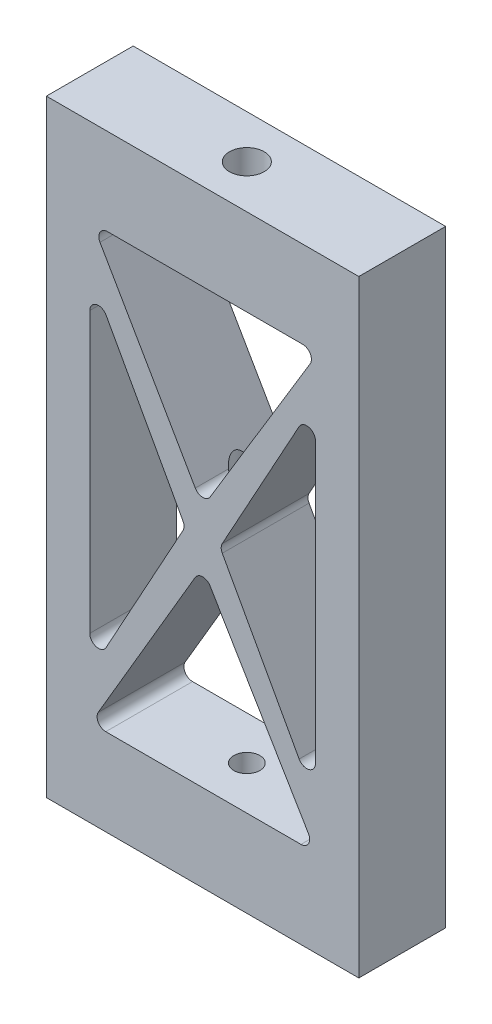
from build123d import *

# Parameters (mm, degrees)
SKIZZE1_W                       = 36
SKIZZE1_H                       = 70
AUFSATZ_LINEAR_AUSTRAGEN1_DEPTH = 10
SKIZZE2_R                       = 1.5
SCHNITT_LINEAR_AUSTRAGEN1_DEPTH = 71
SKIZZE3_R                       = 2
SCHNITT_LINEAR_AUSTRAGEN2_DEPTH = 6
SKIZZE4_R                       = 2
SCHNITT_LINEAR_AUSTRAGEN3_DEPTH = 6


with BuildPart() as part:
    # Skizze1 → Aufsatz-Linear austragen1 (new body)
    with BuildSketch(Plane.XY):
        with Locations((4.904225341, 35)):
            Rectangle(SKIZZE1_W, SKIZZE1_H)
        with BuildLine():
            Line((17.904225341, 51.106779598), (17.904225341, 18.893220402))
            ThreePointArc((17.904225341, 18.893220402), (17.153006461, 17.92466067), (16.028009433, 18.411301652))
            Line((16.028009433, 18.411301652), (7.169280654, 34.51808125))
            ThreePointArc((7.169280654, 34.51808125), (7.045496562, 35), (7.169280654, 35.48191875))
            Line((7.169280654, 35.48191875), (16.028009433, 51.588698348))
            ThreePointArc((16.028009433, 51.588698348), (17.153006461, 52.07533933), (17.904225341, 51.106779598))
        make_face(mode=Mode.SUBTRACT)
        with BuildLine():
            Line((-8.095774659, 51.106779598), (-8.095774659, 18.893220402))
            ThreePointArc((-8.095774659, 18.893220402), (-7.344555779, 17.92466067), (-6.21955875, 18.411301652))
            Line((-6.21955875, 18.411301652), (2.639170029, 34.51808125))
            ThreePointArc((2.639170029, 34.51808125), (2.76295412, 35), (2.639170029, 35.48191875))
            Line((2.639170029, 35.48191875), (-6.21955875, 51.588698348))
            ThreePointArc((-6.21955875, 51.588698348), (-7.344555779, 52.07533933), (-8.095774659, 51.106779598))
        make_face(mode=Mode.SUBTRACT)
        with BuildLine():
            Line((-6.053662963, 60), (16.441312792, 60))
            ThreePointArc((16.441312792, 60), (17.312422464, 59.491088524), (17.296896718, 58.482335877))
            Line((17.296896718, 58.482335877), (5.780402017, 39.448125623))
            ThreePointArc((5.780402017, 39.448125623), (4.914343105, 38.96584461), (4.058577468, 39.466162699))
            Line((4.058577468, 39.466162699), (-6.919903585, 58.500372954))
            ThreePointArc((-6.919903585, 58.500372954), (-6.919580698, 59.500186442), (-6.053662963, 60))
        make_face(mode=Mode.SUBTRACT)
        with BuildLine():
            Line((-6.25411364, 10), (16.240977478, 10))
            ThreePointArc((16.240977478, 10), (17.110316116, 10.505783111), (17.100261151, 11.511499334))
            Line((17.100261151, 11.511499334), (5.769851759, 30.545807203))
            ThreePointArc((5.769851759, 30.545807203), (4.907341379, 31.034302663), (4.048001406, 30.540251269))
            Line((4.048001406, 30.540251269), (-7.116680319, 11.5059434))
            ThreePointArc((-7.116680319, 11.5059434), (-7.121853059, 10.502980584), (-6.25411364, 10))
        make_face(mode=Mode.SUBTRACT)
    extrude(amount=AUFSATZ_LINEAR_AUSTRAGEN1_DEPTH)

    # Skizze2 → Schnitt-Linear austragen1 (cut, through all)
    with BuildSketch(Plane(origin=(0, 70, 0), x_dir=(1, 0, 0), z_dir=(0, 1, 0))):
        with Locations((5, -5)):
            Circle(SKIZZE2_R)
    extrude(amount=-SCHNITT_LINEAR_AUSTRAGEN1_DEPTH, mode=Mode.SUBTRACT)

    # Skizze3 → Schnitt-Linear austragen2 (cut)
    with BuildSketch(Plane(origin=(0, 70, 0), x_dir=(1, 0, 0), z_dir=(0, 1, 0))):
        with Locations((5, -5)):
            Circle(SKIZZE3_R)
    extrude(amount=-SCHNITT_LINEAR_AUSTRAGEN2_DEPTH, mode=Mode.SUBTRACT)

    # Skizze4 → Schnitt-Linear austragen3 (cut)
    with BuildSketch(Plane.XZ):
        with Locations((5, 5)):
            Circle(SKIZZE4_R)
    extrude(amount=-SCHNITT_LINEAR_AUSTRAGEN3_DEPTH, mode=Mode.SUBTRACT)


solid = part.part
